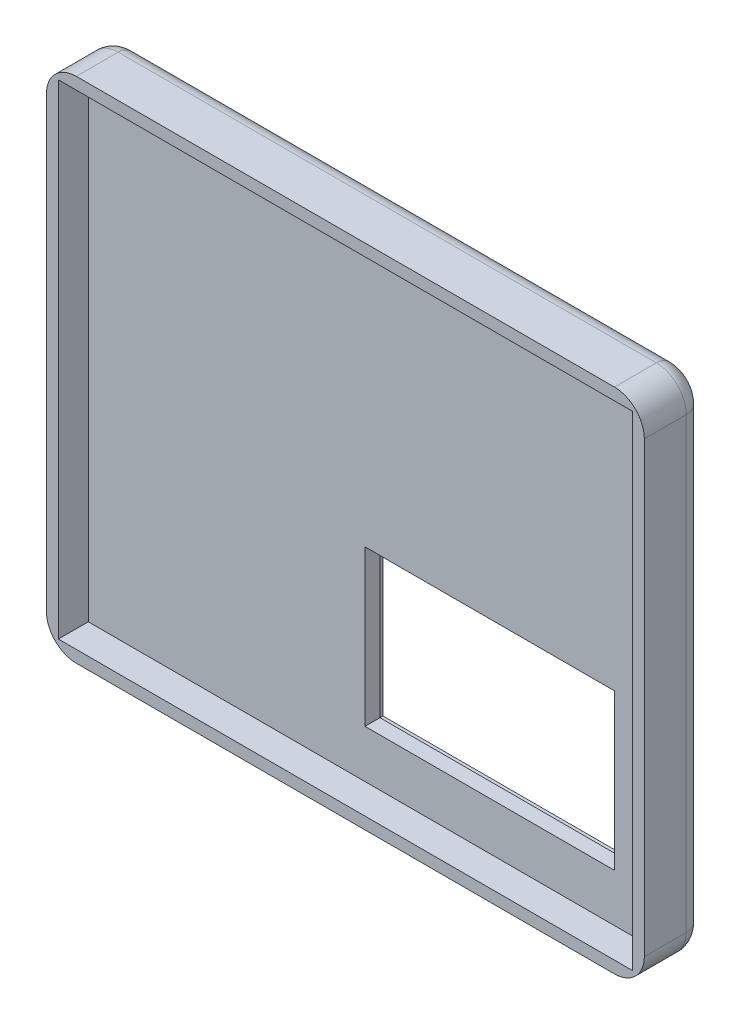
from build123d import *

# Parameters (mm, degrees)
SKETCH1_W           = 100
SKETCH1_H           = 85
BOSS_EXTRUDE1_DEPTH = 5
SKETCH4_W           = 100
SKETCH4_H           = 85
SKETCH4_W_2         = 96
SKETCH4_H_2         = 81
BOSS_EXTRUDE3_DEPTH = 10
FILLET1_R           = 5
FILLET2_R           = 3
SKETCH8_W           = 45.72
SKETCH8_H           = 30
CUT_EXTRUDE3_DEPTH  = 2.5
SKETCH9_W           = 41.72
SKETCH9_H           = 26
CUT_EXTRUDE4_DEPTH  = 100


with BuildPart() as part:
    # Sketch1 → Boss-Extrude1 (new body)
    with BuildSketch(Plane.XY):
        Rectangle(SKETCH1_W, SKETCH1_H)
    extrude(amount=BOSS_EXTRUDE1_DEPTH)

    # Sketch4 → Boss-Extrude3 (add)
    with BuildSketch(Plane(origin=(0, 0, 0), x_dir=(-1, 0, 0), z_dir=(0, 0, -1))):
        Rectangle(SKETCH4_W, SKETCH4_H)
        Rectangle(SKETCH4_W_2, SKETCH4_H_2, mode=Mode.SUBTRACT)
    extrude(amount=-BOSS_EXTRUDE3_DEPTH)

    # Fillet1
    fillet1_edges = [part.edges().sort_by_distance(p)[0] for p in [
        (50, -42.5, 5),
        (-50, -42.5, 5),
        (-50, 42.5, 5),
        (50, 42.5, 5),
    ]]
    fillet(fillet1_edges, radius=FILLET1_R)

    # Fillet2
    fillet2_edges = [part.edges().sort_by_distance(p)[0] for p in [
        (0, -42.5, 0),
        (50, 0, 0),
        (-50, 0, 0),
        (0, 42.5, 0),
        (-48.535533906, 41.035533906, 0),
        (48.535533906, 41.035533906, 0),
        (48.535533906, -41.035533906, 0),
        (-48.535533906, -41.035533906, 0),
    ]]
    fillet(fillet2_edges, radius=FILLET2_R)

    # Sketch8 → Cut-Extrude3 (cut)
    with BuildSketch(Plane(origin=(0, 0, 0), x_dir=(-1, 0, 0), z_dir=(0, 0, -1))):
        with Locations((-19.14, -19.5)):
            Rectangle(SKETCH8_W, SKETCH8_H)
    extrude(amount=-CUT_EXTRUDE3_DEPTH, mode=Mode.SUBTRACT)

    # Sketch9 → Cut-Extrude4 (cut)
    with BuildSketch(Plane(origin=(0, 0, 2.5), x_dir=(-1, 0, 0), z_dir=(0, 0, -1))):
        with Locations((-19.14, -19.5)):
            Rectangle(SKETCH9_W, SKETCH9_H)
    extrude(amount=-CUT_EXTRUDE4_DEPTH, mode=Mode.SUBTRACT)


solid = part.part
